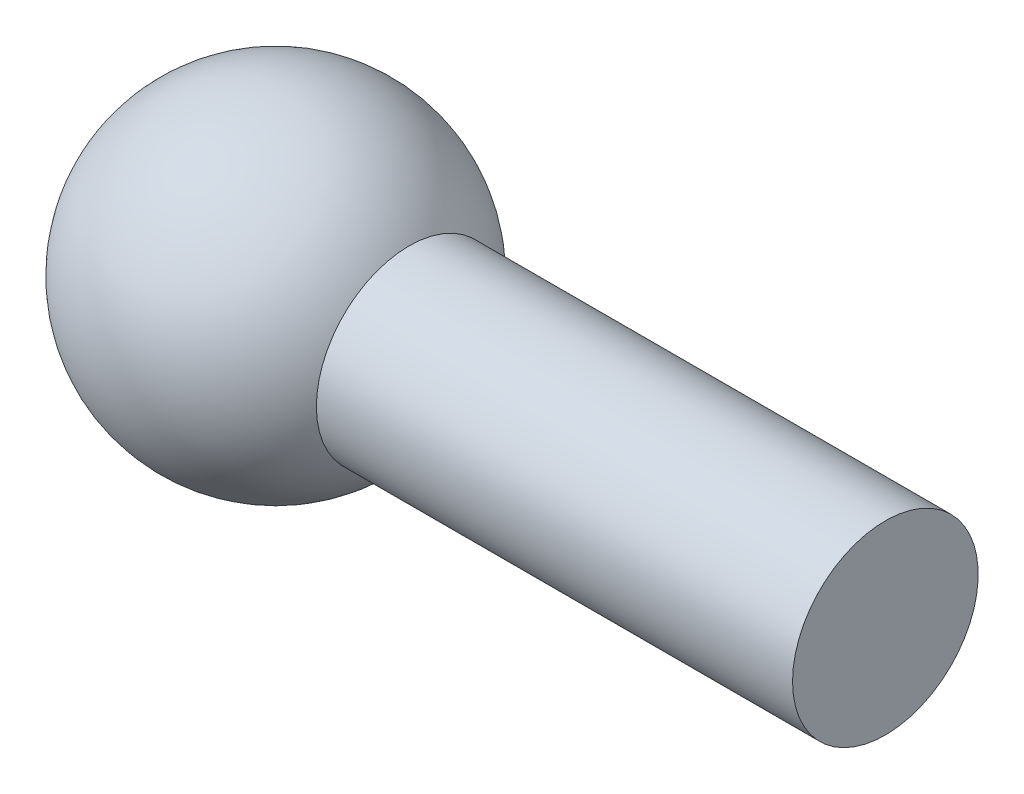
from build123d import *


with BuildPart() as part:
    # Sketch2 → Revolve-Thin1 (revolve)
    with BuildSketch(Plane.XY):
        with BuildLine():
            ThreePointArc((10, 0), (0, 10), (-10, 0))
            Line((-10, 0), (-20, 0))
            ThreePointArc((-20, 0), (0, 20), (20, 0))
            Line((20, 0), (10, 0))
        make_face()
    revolve(axis=Axis((-10, 0, 0), (1, 0, 0)))

    # Sketch3 → Revolve-Thin2 (revolve)
    with BuildSketch(Plane.XY):
        Polygon((15, 0), (15, 11.417573163), (75, 11.417573163), (75, 0), (65, 0), (65, 1.417573163), (25, 1.417573163), (25, 0), align=None)
    revolve(axis=Axis((15, 0, 0), (1, 0, 0)))


solid = part.part
